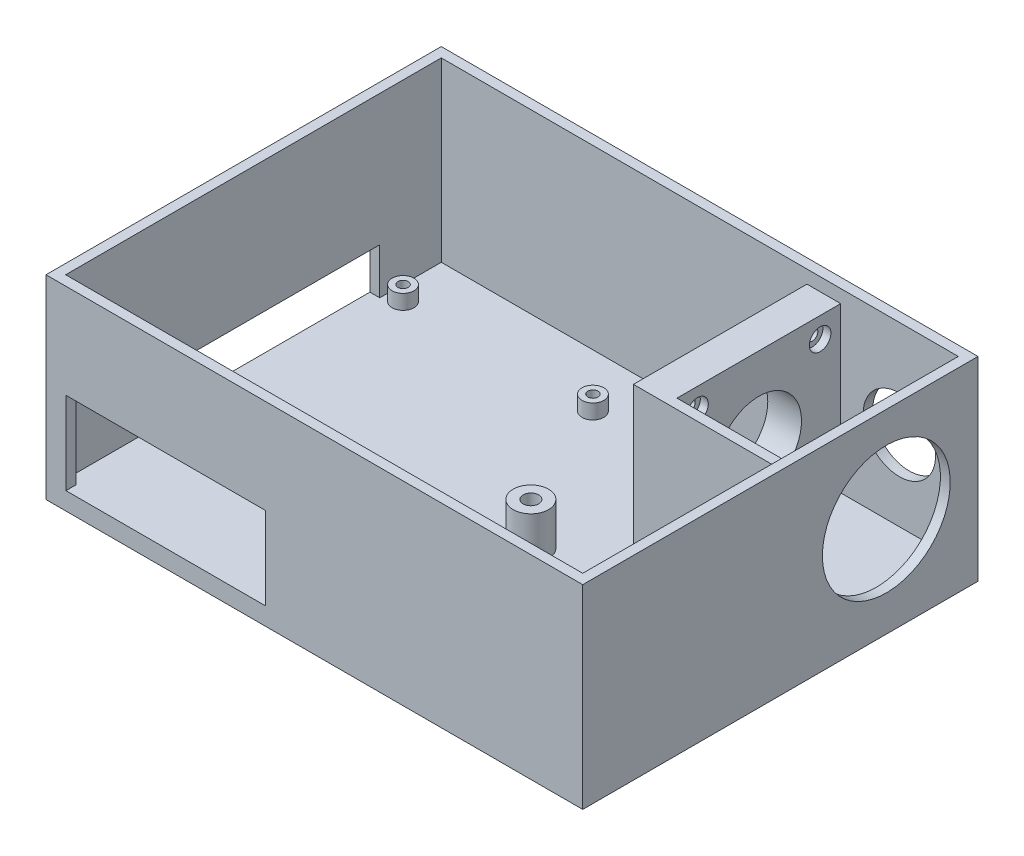
from build123d import *

# Parameters (mm, degrees)
SKETCH1_W           = 138.642720905
SKETCH1_H           = 102.098558723
BOSS_EXTRUDE1_DEPTH = 4.572
SKETCH2_W           = 138.642720905
SKETCH2_H           = 102.098558723
BOSS_EXTRUDE2_DEPTH = 45.72
CUT_EXTRUDE2_DEPTH  = 45.72
BOSS_EXTRUDE3_DEPTH = 3.81
CUT_EXTRUDE3_START  = -15.748
SKETCH6_R           = 1.3208
CUT_EXTRUDE3_DEPTH  = 15.748
SKETCH7_R           = 1.5494
SKETCH7_R_2         = 1.5748
CUT_EXTRUDE4_DEPTH  = 3.9878
SKETCH9_W           = 51.562
SKETCH9_H           = 21.336
CUT_EXTRUDE5_DEPTH  = 13.3858
SKETCH10_W          = 8.7122
SKETCH10_H          = 42.291
BOSS_EXTRUDE4_DEPTH = 42.3418
CUT_EXTRUDE6_DEPTH  = 42.3418
SKETCH12_R          = 1.4605
CUT_EXTRUDE9_DEPTH  = 42.3418
SKETCH15_R          = 2.7813
CUT_EXTRUDE10_DEPTH = 2.0574
SKETCH16_W          = 39.100120905
SKETCH16_H          = 2.54
BOSS_EXTRUDE5_DEPTH = 42.3418
SKETCH17_R          = 1.4478
CUT_EXTRUDE11_DEPTH = 15.0114
BOSS_EXTRUDE6_START = 10.922
SKETCH18_R          = 2.667
SKETCH18_R_2        = 1.4478
BOSS_EXTRUDE6_DEPTH = 10.922
SKETCH19_R          = 2.0193
CUT_EXTRUDE12_DEPTH = 6.2738
SKETCH20_R          = 4.572
SKETCH20_R_2        = 2.0193
BOSS_EXTRUDE7_DEPTH = 10.922
CUT_EXTRUDE13_START = -46.1518
SKETCH21_R          = 11.0236
CUT_EXTRUDE13_DEPTH = 46.1518
SKETCH23_R          = 16.51
CUT_EXTRUDE14_DEPTH = 61.1378
CUT_EXTRUDE15_DEPTH = 15.1638
SKETCH27_W          = 50.8
SKETCH27_H          = 2.471398423
CUT_EXTRUDE16_DEPTH = 15.1638
BOSS_EXTRUDE8_DEPTH = 2.54
BOSS_EXTRUDE9_DEPTH = 2.54


with BuildPart() as part:
    # Sketch1 → Boss-Extrude1 (new body)
    with BuildSketch(Plane(origin=(0, 0, 0), x_dir=(1, 0, 0), z_dir=(0, 1, 0))):
        with Locations((69.321360453, 51.049279362)):
            Rectangle(SKETCH1_W, SKETCH1_H)
    extrude(amount=BOSS_EXTRUDE1_DEPTH)

    # Sketch2 → Boss-Extrude2 (add)
    with BuildSketch(Plane(origin=(0, 4.572, 0), x_dir=(1, 0, 0), z_dir=(0, 1, 0))):
        with Locations((69.321360453, 51.049279362)):
            Rectangle(SKETCH2_W, SKETCH2_H)
        Polygon((2.54, 99.558558723), (69.321360452, 99.558558723), (136.102720905, 99.558558723), (136.102720905, 51.049279362), (136.102720905, 2.54), (2.54, 2.54), align=None, mode=Mode.SUBTRACT)
    extrude(amount=BOSS_EXTRUDE2_DEPTH)

    # Sketch4 → Cut-Extrude2 (cut)
    with BuildSketch(Plane.ZY):
        with BuildLine():
            Line((-83.6676, 4.572), (-51.049279362, 4.572))
            Line((-51.049279362, 4.572), (-32.8676, 4.572))
            ThreePointArc((-32.8676, 4.572), (-30.92121047, 9.271), (-32.8676, 13.97))
            Line((-32.8676, 13.97), (-83.6676, 13.97))
            ThreePointArc((-83.6676, 13.97), (-85.61398953, 9.271), (-83.6676, 4.572))
        make_face()
    extrude(amount=-CUT_EXTRUDE2_DEPTH, mode=Mode.SUBTRACT)

    # Sketch5 → Boss-Extrude3 (add)
    with BuildSketch(Plane(origin=(0, 4.572, 0), x_dir=(1, 0, 0), z_dir=(0, 1, 0))):
        with BuildLine():
            ThreePointArc((9.1948, 27.94), (8.369016859, 29.933616859), (6.3754, 30.7594))
            Line((6.3754, 30.7594), (6.3754, 29.2608))
            ThreePointArc((6.3754, 29.2608), (7.309346637, 28.873946637), (7.6962, 27.94))
            Line((7.6962, 27.94), (9.1948, 27.94))
        make_face()
        with BuildLine():
            Line((5.0546, 27.94), (3.556, 27.94))
            ThreePointArc((3.556, 27.94), (6.3754, 25.1206), (9.1948, 27.94))
            Line((9.1948, 27.94), (7.6962, 27.94))
            ThreePointArc((7.6962, 27.94), (6.3754, 26.6192), (5.0546, 27.94))
        make_face()
        with BuildLine():
            ThreePointArc((6.3754, 30.7594), (4.381783141, 29.933616859), (3.556, 27.94))
            Line((3.556, 27.94), (5.0546, 27.94))
            ThreePointArc((5.0546, 27.94), (5.441453363, 28.873946637), (6.3754, 29.2608))
            Line((6.3754, 29.2608), (6.3754, 30.7594))
        make_face()
        with BuildLine():
            ThreePointArc((55.4228, 30.7594), (53.429183141, 29.933616859), (52.6034, 27.94))
            Line((52.6034, 27.94), (54.102, 27.94))
            ThreePointArc((54.102, 27.94), (54.488853363, 28.873946637), (55.4228, 29.2608))
            Line((55.4228, 29.2608), (55.4228, 30.7594))
        make_face()
        with BuildLine():
            Line((54.102, 27.94), (52.6034, 27.94))
            ThreePointArc((52.6034, 27.94), (55.4228, 25.1206), (58.2422, 27.94))
            ThreePointArc((58.2422, 27.94), (57.416416859, 29.933616859), (55.4228, 30.7594))
            Line((55.4228, 30.7594), (55.4228, 29.2608))
            ThreePointArc((55.4228, 29.2608), (56.356746637, 28.873946637), (56.7436, 27.94))
            ThreePointArc((56.7436, 27.94), (55.4228, 26.6192), (54.102, 27.94))
        make_face()
        with BuildLine():
            ThreePointArc((58.2422, 85.852), (55.4228, 88.6714), (52.6034, 85.852))
            Line((52.6034, 85.852), (54.102, 85.852))
            ThreePointArc((54.102, 85.852), (55.4228, 87.1728), (56.7436, 85.852))
            ThreePointArc((56.7436, 85.852), (56.356746637, 84.918053363), (55.4228, 84.5312))
            Line((55.4228, 84.5312), (55.4228, 83.0326))
            ThreePointArc((55.4228, 83.0326), (57.416416859, 83.858383141), (58.2422, 85.852))
        make_face()
        with BuildLine():
            Line((54.102, 85.852), (52.6034, 85.852))
            ThreePointArc((52.6034, 85.852), (53.429183141, 83.858383141), (55.4228, 83.0326))
            Line((55.4228, 83.0326), (55.4228, 84.5312))
            ThreePointArc((55.4228, 84.5312), (54.488853363, 84.918053363), (54.102, 85.852))
        make_face()
        with BuildLine():
            ThreePointArc((9.1948, 85.852), (4.381783141, 87.845616859), (6.3754, 83.0326))
            Line((6.3754, 83.0326), (6.3754, 84.5312))
            ThreePointArc((6.3754, 84.5312), (5.441453363, 86.785946637), (7.6962, 85.852))
            Line((7.6962, 85.852), (9.1948, 85.852))
        make_face()
        with BuildLine():
            Line((6.3754, 84.5312), (6.3754, 83.0326))
            ThreePointArc((6.3754, 83.0326), (8.369016859, 83.858383141), (9.1948, 85.852))
            Line((9.1948, 85.852), (7.6962, 85.852))
            ThreePointArc((7.6962, 85.852), (7.309346637, 84.918053363), (6.3754, 84.5312))
        make_face()
    extrude(amount=BOSS_EXTRUDE3_DEPTH)

    # Sketch6 → Cut-Extrude3 (cut)
    with BuildSketch(Plane(origin=(0, 4.572, 0), x_dir=(1, 0, 0), z_dir=(0, 1, 0)).offset(CUT_EXTRUDE3_START)):
        with Locations(Location((6.3754, 27.94, 0), (0, 0, 90))):
            Circle(SKETCH6_R)
        with Locations(Location((55.4228, 27.94, 0), (0, 0, 90))):
            Circle(SKETCH6_R)
        with Locations(Location((55.4228, 85.852, 0), (0, 0, 90))):
            Circle(SKETCH6_R)
        with Locations(Location((6.3754, 85.852, 0), (0, 0, 90))):
            Circle(SKETCH6_R)
    extrude(amount=CUT_EXTRUDE3_DEPTH, mode=Mode.SUBTRACT)

    # Sketch7 → Cut-Extrude4 (cut)
    with BuildSketch(Plane.XZ):
        with Locations(Location((6.3754, -27.94, 0), (0, 0, 270))):
            Circle(SKETCH7_R)
        with Locations(Location((55.4228, -27.94, 0), (0, 0, 270))):
            Circle(SKETCH7_R_2)
        with Locations(Location((55.4228, -85.852, 0), (0, 0, 270))):
            Circle(SKETCH7_R_2)
        with Locations(Location((6.3754, -85.852, 0), (0, 0, 270))):
            Circle(SKETCH7_R_2)
    extrude(amount=-CUT_EXTRUDE4_DEPTH, mode=Mode.SUBTRACT)

    # Sketch9 → Cut-Extrude5 (cut)
    with BuildSketch(Plane.XY):
        with Locations((30.9372, 15.24)):
            Rectangle(SKETCH9_W, SKETCH9_H)
    extrude(amount=-CUT_EXTRUDE5_DEPTH, mode=Mode.SUBTRACT)

    # Sketch10 → Boss-Extrude4 (add)
    with BuildSketch(Plane(origin=(0, 4.572, 0), x_dir=(1, 0, 0), z_dir=(0, 1, 0))):
        with Locations((101.3587, 78.413058723)):
            Rectangle(SKETCH10_W, SKETCH10_H)
    extrude(amount=BOSS_EXTRUDE4_DEPTH)

    # Sketch11 → Cut-Extrude6 (cut)
    with BuildSketch(Plane(origin=(105.7148, 0, 0), x_dir=(0, 0, -1), z_dir=(1, 0, 0))):
        with BuildLine():
            ThreePointArc((89.436658723, 25.7429), (88.596270608, 29.964505461), (86.203240844, 33.542439697))
            Line((86.203240844, 33.542439697), (78.413058723, 25.7429))
            Line((78.413058723, 25.7429), (86.203240844, 17.943360303))
            ThreePointArc((86.203240844, 17.943360303), (88.596270608, 21.521294539), (89.436658723, 25.7429))
        make_face()
        with BuildLine():
            Line((78.413058723, 25.7429), (86.203240844, 33.542439697))
            ThreePointArc((86.203240844, 33.542439697), (78.413058723, 36.7665), (70.622876602, 33.542439697))
            Line((70.622876602, 33.542439697), (78.413058723, 25.7429))
        make_face()
        with BuildLine():
            Line((86.203240844, 17.943360303), (78.413058723, 25.7429))
            Line((78.413058723, 25.7429), (70.622876602, 17.943360303))
            ThreePointArc((70.622876602, 17.943360303), (78.413058723, 14.7193), (86.203240844, 17.943360303))
        make_face()
        with BuildLine():
            Line((70.622876602, 17.943360303), (78.413058723, 25.7429))
            Line((78.413058723, 25.7429), (70.622876602, 33.542439697))
            ThreePointArc((70.622876602, 33.542439697), (67.389458723, 25.7429), (70.622876602, 17.943360303))
        make_face()
    extrude(amount=-CUT_EXTRUDE6_DEPTH, mode=Mode.SUBTRACT)

    # Sketch12 → Cut-Extrude9 (cut)
    with BuildSketch(Plane(origin=(105.7148, 0, 0), x_dir=(0, 0, -1), z_dir=(1, 0, 0))):
        with Locations((94.249958723, 9.8806)):
            Circle(SKETCH12_R)
        with Locations((62.576158723, 9.8806)):
            Circle(SKETCH12_R)
        with Locations((94.249958723, 41.6052)):
            Circle(SKETCH12_R)
        with Locations((62.576158723, 41.6052)):
            Circle(SKETCH12_R)
    extrude(amount=-CUT_EXTRUDE9_DEPTH, mode=Mode.SUBTRACT)

    # Sketch15 → Cut-Extrude10 (cut)
    with BuildSketch(Plane(origin=(105.7148, 0, 0), x_dir=(0, 0, -1), z_dir=(1, 0, 0))):
        with Locations((62.576158723, 41.6052)):
            Circle(SKETCH15_R)
        with Locations((94.249958723, 41.6052)):
            Circle(SKETCH15_R)
        with Locations((62.576158723, 9.8806)):
            Circle(SKETCH15_R)
        with Locations((94.249958723, 9.8806)):
            Circle(SKETCH15_R)
    extrude(amount=-CUT_EXTRUDE10_DEPTH, mode=Mode.SUBTRACT)

    # Sketch16 → Boss-Extrude5 (add)
    with BuildSketch(Plane(origin=(0, 4.572, 0), x_dir=(1, 0, 0), z_dir=(0, 1, 0))):
        with Locations((116.552660453, 55.997558723)):
            Rectangle(SKETCH16_W, SKETCH16_H)
    extrude(amount=BOSS_EXTRUDE5_DEPTH)

    # Sketch17 → Cut-Extrude11 (cut)
    with BuildSketch(Plane(origin=(0, 4.572, 0), x_dir=(1, 0, 0), z_dir=(0, 1, 0))):
        with Locations(Location((78.074628339, 47.169331877, 0), (0, 0, 270))):
            Circle(SKETCH17_R)
        with Locations(Location((115.438028339, 47.169331877, 0), (0, 0, 270))):
            Circle(SKETCH17_R)
        with Locations(Location((115.438028339, 9.805931877, 0), (0, 0, 270))):
            Circle(SKETCH17_R)
        with Locations(Location((78.074628339, 9.805931877, 0), (0, 0, 270))):
            Circle(SKETCH17_R)
    extrude(amount=-CUT_EXTRUDE11_DEPTH, mode=Mode.SUBTRACT)

    # Sketch18 → Boss-Extrude6 (add)
    # profile 1 of 4: a face of its own
    with BuildSketch(Plane(origin=(0, 4.572, 0), x_dir=(1, 0, 0), z_dir=(0, 1, 0)).offset(BOSS_EXTRUDE6_START)):
        with Locations(Location((78.074628339, 47.169331877, 0), (0, 0, 270))):
            Circle(SKETCH18_R)
        with Locations(Location((78.074628339, 47.169331877, 0), (0, 0, 270))):
            Circle(SKETCH18_R_2, mode=Mode.SUBTRACT)
    # profile 2 of 4: a face of its own
    with BuildSketch(Plane(origin=(0, 4.572, 0), x_dir=(1, 0, 0), z_dir=(0, 1, 0)).offset(BOSS_EXTRUDE6_START)):
        with Locations(Location((115.438028339, 47.169331877, 0), (0, 0, 270))):
            Circle(SKETCH18_R)
        with Locations(Location((115.438028339, 47.169331877, 0), (0, 0, 270))):
            Circle(SKETCH18_R_2, mode=Mode.SUBTRACT)
    # profile 3 of 4: a face of its own
    with BuildSketch(Plane(origin=(0, 4.572, 0), x_dir=(1, 0, 0), z_dir=(0, 1, 0)).offset(BOSS_EXTRUDE6_START)):
        with Locations(Location((115.438028339, 9.805931877, 0), (0, 0, 270))):
            Circle(SKETCH18_R)
        with Locations(Location((115.438028339, 9.805931877, 0), (0, 0, 270))):
            Circle(SKETCH18_R_2, mode=Mode.SUBTRACT)
    # profile 4 of 4: a face of its own
    with BuildSketch(Plane(origin=(0, 4.572, 0), x_dir=(1, 0, 0), z_dir=(0, 1, 0)).offset(BOSS_EXTRUDE6_START)):
        with Locations(Location((78.074628339, 9.805931877, 0), (0, 0, 270))):
            Circle(SKETCH18_R)
        with Locations(Location((78.074628339, 9.805931877, 0), (0, 0, 270))):
            Circle(SKETCH18_R_2, mode=Mode.SUBTRACT)
    extrude(amount=-BOSS_EXTRUDE6_DEPTH)

    # Sketch19 → Cut-Extrude12 (cut)
    with BuildSketch(Plane(origin=(0, 15.494, 0), x_dir=(1, 0, 0), z_dir=(0, 1, 0))):
        with Locations(Location((115.438028339, 9.805931877, 0), (0, 0, 270))):
            Circle(SKETCH19_R)
        with Locations(Location((78.074628339, 9.805931877, 0), (0, 0, 270))):
            Circle(SKETCH19_R)
        with Locations(Location((115.438028339, 47.169331877, 0), (0, 0, 270))):
            Circle(SKETCH19_R)
        with Locations(Location((78.074628339, 47.169331877, 0), (0, 0, 270))):
            Circle(SKETCH19_R)
    extrude(amount=-CUT_EXTRUDE12_DEPTH, mode=Mode.SUBTRACT)

    # Sketch20 → Boss-Extrude7 (add)
    # profile 1 of 4: a face of its own
    with BuildSketch(Plane(origin=(0, 15.494, 0), x_dir=(1, 0, 0), z_dir=(0, 1, 0))):
        with Locations(Location((78.074628339, 9.805931877, 0), (0, 0, 270))):
            Circle(SKETCH20_R)
        with Locations(Location((78.074628339, 9.805931877, 0), (0, 0, 270))):
            Circle(SKETCH20_R_2, mode=Mode.SUBTRACT)
    # profile 2 of 4: a face of its own
    with BuildSketch(Plane(origin=(0, 15.494, 0), x_dir=(1, 0, 0), z_dir=(0, 1, 0))):
        with Locations(Location((115.438028339, 9.805931877, 0), (0, 0, 270))):
            Circle(SKETCH20_R)
        with Locations(Location((115.438028339, 9.805931877, 0), (0, 0, 270))):
            Circle(SKETCH20_R_2, mode=Mode.SUBTRACT)
    # profile 3 of 4: a face of its own
    with BuildSketch(Plane(origin=(0, 15.494, 0), x_dir=(1, 0, 0), z_dir=(0, 1, 0))):
        with Locations(Location((115.438028339, 47.169331877, 0), (0, 0, 270))):
            Circle(SKETCH20_R)
        with Locations(Location((115.438028339, 47.169331877, 0), (0, 0, 270))):
            Circle(SKETCH20_R_2, mode=Mode.SUBTRACT)
    # profile 4 of 4: a face of its own
    with BuildSketch(Plane(origin=(0, 15.494, 0), x_dir=(1, 0, 0), z_dir=(0, 1, 0))):
        with Locations(Location((78.074628339, 47.169331877, 0), (0, 0, 270))):
            Circle(SKETCH20_R)
        with Locations(Location((78.074628339, 47.169331877, 0), (0, 0, 270))):
            Circle(SKETCH20_R_2, mode=Mode.SUBTRACT)
    extrude(amount=-BOSS_EXTRUDE7_DEPTH)

    # Sketch21 → Cut-Extrude13 (cut)
    with BuildSketch(Plane.ZY.offset(-97.0026).offset(CUT_EXTRUDE13_START)):
        with Locations(Location((-78.413058723, 25.7429, 0), (0, 0, 180))):
            Circle(SKETCH21_R)
    extrude(amount=CUT_EXTRUDE13_DEPTH, mode=Mode.SUBTRACT)

    # Sketch23 → Cut-Extrude14 (cut)
    with BuildSketch(Plane(origin=(105.7148, 0, 0), x_dir=(0, 0, -1), z_dir=(1, 0, 0))):
        with Locations(Location((78.413058723, 25.7429, 0), (0, 0, 180))):
            Circle(SKETCH23_R)
    extrude(amount=CUT_EXTRUDE14_DEPTH, mode=Mode.SUBTRACT)

    # Sketch25 → Cut-Extrude15 (cut)
    with BuildSketch(Plane(origin=(0, 0, -102.098558723), x_dir=(-1, 0, 0), z_dir=(0, 0, -1))):
        with BuildLine():
            ThreePointArc((-111.503030932, 25.146), (-120.862720905, 34.505689972), (-130.222410877, 25.146))
            Line((-130.222410877, 25.146), (-111.503030932, 25.146))
        make_face()
        with BuildLine():
            Line((-111.503030932, 25.146), (-130.222410877, 25.146))
            ThreePointArc((-130.222410877, 25.146), (-120.862720905, 15.786310028), (-111.503030932, 25.146))
        make_face()
    extrude(amount=-CUT_EXTRUDE15_DEPTH, mode=Mode.SUBTRACT)

    # Sketch27 → Cut-Extrude16 (cut)
    with BuildSketch(Plane.ZY):
        with Locations((-58.2676, 15.205699212)):
            Rectangle(SKETCH27_W, SKETCH27_H)
    extrude(amount=-CUT_EXTRUDE16_DEPTH, mode=Mode.SUBTRACT)

    # Sketch28 → Boss-Extrude8 (add)
    with BuildSketch(Plane.ZY):
        with BuildLine():
            Line((-83.6676, 4.572), (-83.6676, 13.97))
            ThreePointArc((-83.6676, 13.97), (-85.61398953, 9.271), (-83.6676, 4.572))
        make_face()
    extrude(amount=-BOSS_EXTRUDE8_DEPTH)

    # Sketch29 → Boss-Extrude9 (add)
    with BuildSketch(Plane.ZY):
        with BuildLine():
            Line((-32.8676, 13.97), (-32.8676, 4.572))
            ThreePointArc((-32.8676, 4.572), (-30.92121047, 9.271), (-32.8676, 13.97))
        make_face()
    extrude(amount=-BOSS_EXTRUDE9_DEPTH)


solid = part.part
